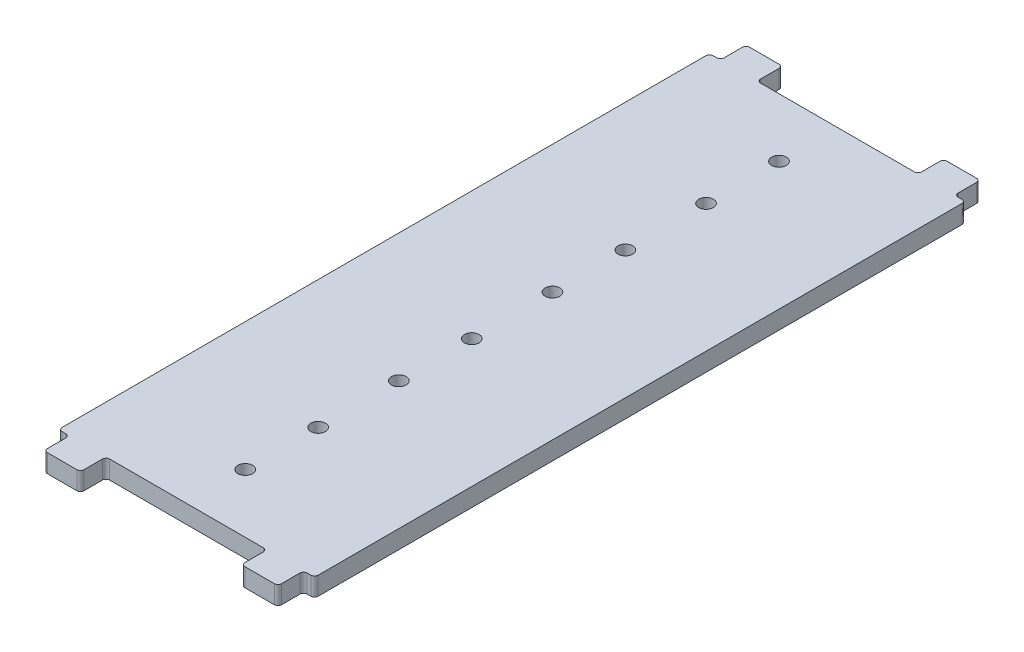
from build123d import *

# Parameters (mm, degrees)
BOSS_EXTRUDE1_DEPTH = 5
SKETCH2_R           = 2
CUT_EXTRUDE1_DEPTH  = 10


with BuildPart() as part:
    # Sketch1 → Boss-Extrude1 (new body)
    with BuildSketch(Plane(origin=(0, 0, 0), x_dir=(1, 0, 0), z_dir=(0, 1, 0))):
        with BuildLine():
            Line((34, -89), (33, -89))
            ThreePointArc((33, -89), (32.292893219, -89.292893219), (32, -90))
            Line((32, -90), (32, -95))
            ThreePointArc((32, -95), (31.707106781, -95.707106781), (31, -96))
            Line((31, -96), (23, -96))
            ThreePointArc((23, -96), (22.292893219, -95.707106781), (22, -95))
            Line((22, -95), (22, -90))
            ThreePointArc((22, -90), (21.707106781, -89.292893219), (21, -89))
            Line((21, -89), (-21, -89))
            ThreePointArc((-21, -89), (-21.707106781, -89.292893219), (-22, -90))
            Line((-22, -90), (-22, -95))
            ThreePointArc((-22, -95), (-22.292893219, -95.707106781), (-23, -96))
            Line((-23, -96), (-31, -96))
            ThreePointArc((-31, -96), (-31.707106781, -95.707106781), (-32, -95))
            Line((-32, -95), (-32, -90))
            ThreePointArc((-32, -90), (-32.292893219, -89.292893219), (-33, -89))
            Line((-33, -89), (-34, -89))
            ThreePointArc((-34, -89), (-34.707106781, -88.707106781), (-35, -88))
            Line((-35, -88), (-35, 88))
            ThreePointArc((-35, 88), (-34.707106781, 88.707106781), (-34, 89))
            Line((-34, 89), (-33, 89))
            ThreePointArc((-33, 89), (-32.292893219, 89.292893219), (-32, 90))
            Line((-32, 90), (-32, 95))
            ThreePointArc((-32, 95), (-31.707106781, 95.707106781), (-31, 96))
            Line((-31, 96), (-23, 96))
            ThreePointArc((-23, 96), (-22.292893219, 95.707106781), (-22, 95))
            Line((-22, 95), (-22, 90))
            ThreePointArc((-22, 90), (-21.707106781, 89.292893219), (-21, 89))
            Line((-21, 89), (21, 89))
            ThreePointArc((21, 89), (21.707106781, 89.292893219), (22, 90))
            Line((22, 90), (22, 95))
            ThreePointArc((22, 95), (22.292893219, 95.707106781), (23, 96))
            Line((23, 96), (31, 96))
            ThreePointArc((31, 96), (31.707106781, 95.707106781), (32, 95))
            Line((32, 95), (32, 90))
            ThreePointArc((32, 90), (32.292893219, 89.292893219), (33, 89))
            Line((33, 89), (34, 89))
            ThreePointArc((34, 89), (34.707106781, 88.707106781), (35, 88))
            Line((35, 88), (35, -88))
            ThreePointArc((35, -88), (34.707106781, -88.707106781), (34, -89))
        make_face()
    extrude(amount=BOSS_EXTRUDE1_DEPTH)

    # Sketch2 → Cut-Extrude1 (cut)
    with BuildSketch(Plane(origin=(0, 5, 0), x_dir=(1, 0, 0), z_dir=(0, 1, 0))):
        with Locations((0, 73)):
            Circle(SKETCH2_R)
        with Locations((0, 53.061)):
            Circle(SKETCH2_R)
        with Locations((0, 11.061)):
            Circle(SKETCH2_R)
        with Locations((0, 31)):
            Circle(SKETCH2_R)
        with Locations((0, -30.939)):
            Circle(SKETCH2_R)
        with Locations((0, -11)):
            Circle(SKETCH2_R)
        with Locations((0, -72.939)):
            Circle(SKETCH2_R)
        with Locations((0, -53)):
            Circle(SKETCH2_R)
    extrude(amount=-CUT_EXTRUDE1_DEPTH, mode=Mode.SUBTRACT)


solid = part.part
